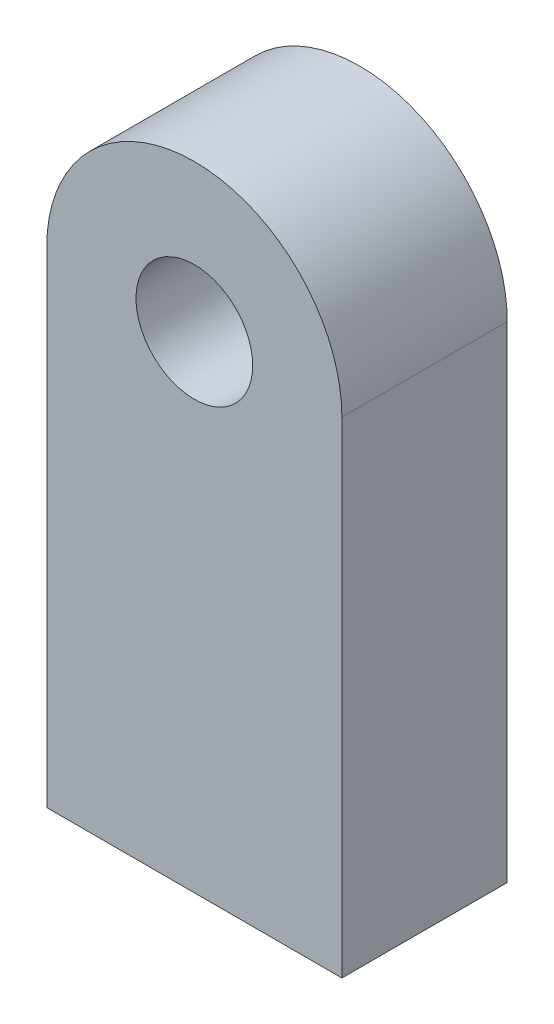
from build123d import *

# Parameters (mm, degrees)
SKETCH1_R           = 3.175
BOSS_EXTRUDE1_DEPTH = 9


with BuildPart() as part:
    # Sketch1 → Boss-Extrude1 (new body)
    with BuildSketch(Plane.XY):
        with BuildLine():
            Line((-8.032782944, 13.219871482), (-8.032782944, -13.219871482))
            Line((-8.032782944, -13.219871482), (8.032782944, -13.219871482))
            Line((8.032782944, -13.219871482), (8.032782944, 13.219871482))
            ThreePointArc((8.032782944, 13.219871482), (5.680035292, 18.899906774), (0, 21.252654427))
            ThreePointArc((0, 21.252654427), (-5.680035292, 18.899906774), (-8.032782944, 13.219871482))
        make_face()
        with Locations((0, 13.219871482)):
            Circle(SKETCH1_R, mode=Mode.SUBTRACT)
    extrude(amount=BOSS_EXTRUDE1_DEPTH)


solid = part.part
